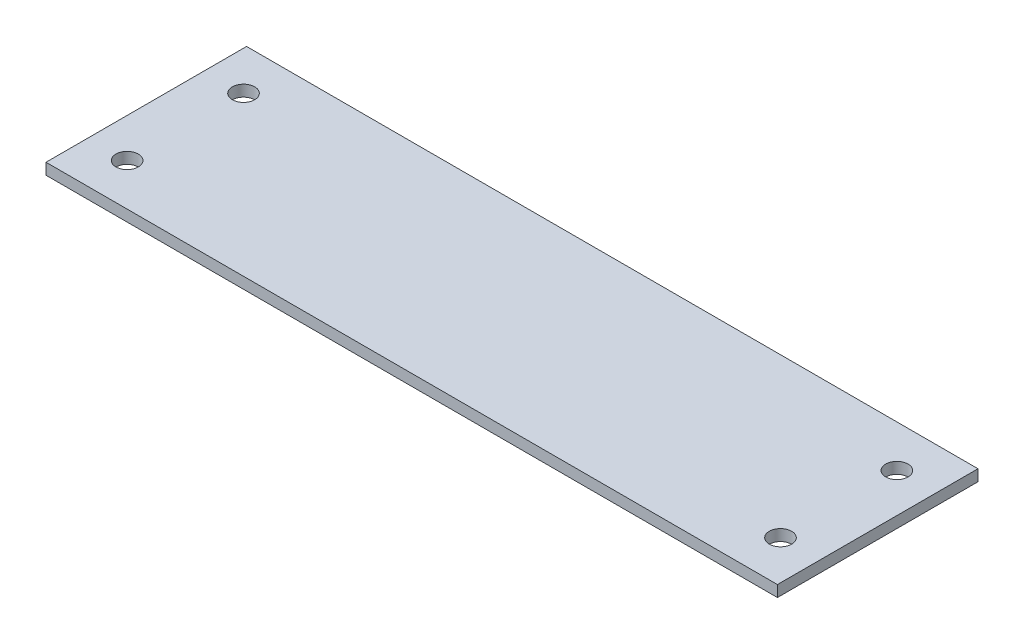
from build123d import *

# Parameters (mm, degrees)
SKETCH1_W           = 103.75
SKETCH1_H           = 28.45
BOSS_EXTRUDE1_DEPTH = 1.6
SKETCH2_R           = 1.5875
CUT_EXTRUDE1_DEPTH  = 2.6


with BuildPart() as part:
    # Sketch1 → Boss-Extrude1 (new body)
    with BuildSketch(Plane(origin=(0, 0, 0), x_dir=(1, 0, 0), z_dir=(0, 1, 0))):
        Rectangle(SKETCH1_W, SKETCH1_H)
    extrude(amount=BOSS_EXTRUDE1_DEPTH)

    # Sketch2 → Cut-Extrude1 (cut, through all)
    with BuildSketch(Plane(origin=(0, 1.6, 0), x_dir=(1, 0, 0), z_dir=(0, 1, 0))):
        with Locations((46.3378, 8.256)):
            Circle(SKETCH2_R)
        with Locations((46.3378, -8.256)):
            Circle(SKETCH2_R)
        with Locations((-46.3378, 8.256)):
            Circle(SKETCH2_R)
        with Locations((-46.3378, -8.256)):
            Circle(SKETCH2_R)
    extrude(amount=-CUT_EXTRUDE1_DEPTH, mode=Mode.SUBTRACT)


solid = part.part
